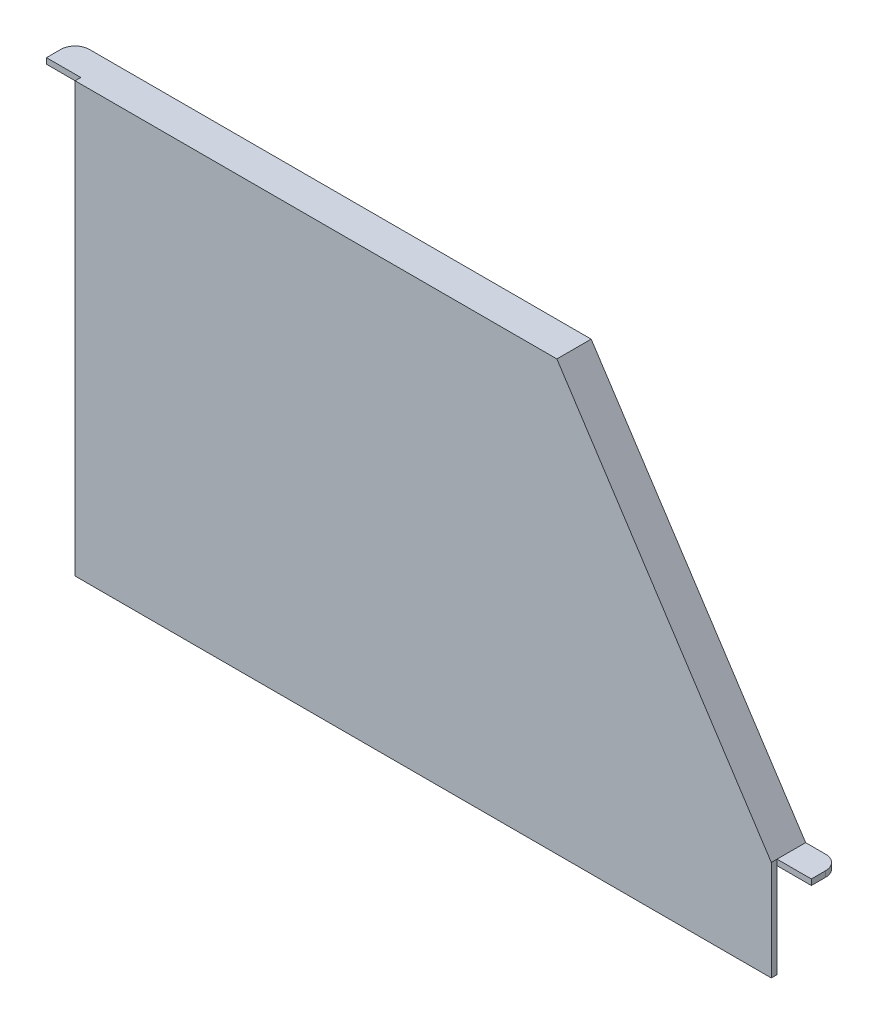
from build123d import *

# Parameters (mm, degrees)
BOSS_EXTRUDE1_DEPTH = 4
SKETCH2_W           = 337
SKETCH2_H           = 4
BOSS_EXTRUDE2_DEPTH = 20
BOSS_EXTRUDE3_DEPTH = 20
SKETCH7_W           = 20
SKETCH7_H           = 4
BOSS_EXTRUDE6_DEPTH = 24
SKETCH8_W           = 20
SKETCH8_H           = 4
BOSS_EXTRUDE7_DEPTH = 24
FILLET1_R           = 10


with BuildPart() as part:
    # Sketch1 → Boss-Extrude1 (new body)
    with BuildSketch(Plane.XY):
        Polygon((0, 0), (0, 300), (337, 300), (487, 70), (487, 0), align=None)
    extrude(amount=BOSS_EXTRUDE1_DEPTH)

    # Sketch2 → Boss-Extrude2 (add)
    with BuildSketch(Plane(origin=(0, 0, 0), x_dir=(-1, 0, 0), z_dir=(0, 0, -1))):
        with Locations((-168.5, 298)):
            Rectangle(SKETCH2_W, SKETCH2_H)
    extrude(amount=BOSS_EXTRUDE2_DEPTH)

    # Sketch3 → Boss-Extrude3 (add)
    with BuildSketch(Plane(origin=(0, 0, 0), x_dir=(-1, 0, 0), z_dir=(0, 0, -1))):
        Polygon((-337, 300), (-337, 296), (-487, 66), (-487, 70), align=None)
    extrude(amount=BOSS_EXTRUDE3_DEPTH)

    # Sketch7 → Boss-Extrude6 (add)
    with BuildSketch(Plane(origin=(487, 0, 0), x_dir=(0, 0, -1), z_dir=(1, 0, 0))):
        with Locations((10, 68)):
            Rectangle(SKETCH7_W, SKETCH7_H)
    extrude(amount=BOSS_EXTRUDE6_DEPTH)

    # Sketch8 → Boss-Extrude7 (add)
    with BuildSketch(Plane.ZY):
        with Locations((-10, 298)):
            Rectangle(SKETCH8_W, SKETCH8_H)
    extrude(amount=BOSS_EXTRUDE7_DEPTH)

    # Fillet1
    fillet1_edges = [part.edges().sort_by_distance(p)[0] for p in [
        (511, 68, -20),
        (-24, 298, -20),
    ]]
    fillet(fillet1_edges, radius=FILLET1_R)


solid = part.part
